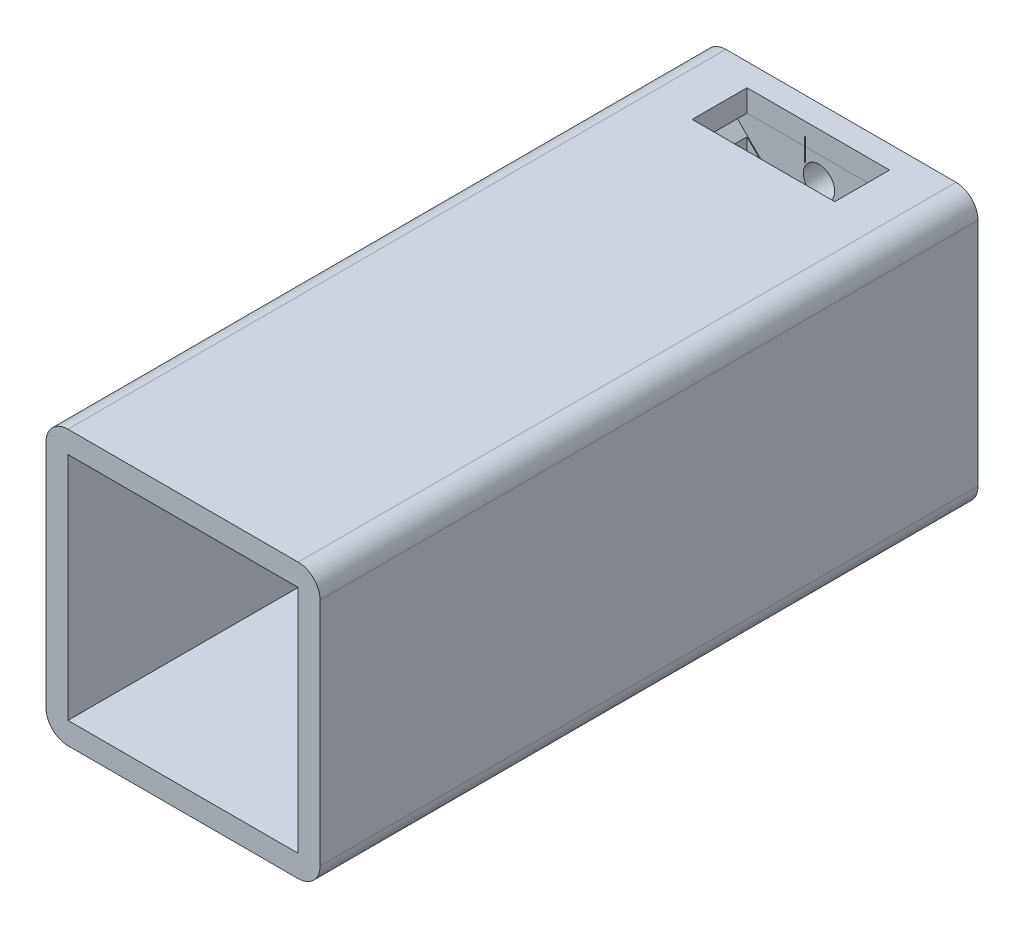
from build123d import *

# Parameters (mm, degrees)
SKETCH1_W           = 25
SKETCH1_H           = 25
BOSS_EXTRUDE1_DEPTH = 60
SHELL1_T            = -2
SKETCH2_R           = 2.5
SKETCH2_R_2         = 1.425
CUT_EXTRUDE4_DEPTH  = 2
BOSS_EXTRUDE3_DEPTH = 30
FILLET1_R           = 2
SKETCH5_W           = 13
SKETCH5_H           = 5
SKETCH5_R           = 0.024622166
CUT_EXTRUDE6_DEPTH  = 10


with BuildPart() as part:
    # Sketch1 → Boss-Extrude1 (new body)
    with BuildSketch(Plane.XY):
        Rectangle(SKETCH1_W, SKETCH1_H)
    extrude(amount=BOSS_EXTRUDE1_DEPTH)

    # Shell1
    shell1_openings = [part.faces().sort_by_distance(p)[0] for p in [
        (0, 0, 60),
    ]]
    offset(amount=SHELL1_T, openings=shell1_openings, kind=Kind.INTERSECTION)

    # Sketch2 → Cut-Extrude4 (cut)
    with BuildSketch(Plane.XY):
        Circle(SKETCH2_R)
        with Locations((8.25, 0)):
            Circle(SKETCH2_R_2)
        with Locations((0, -8.25)):
            Circle(SKETCH2_R_2)
        with Locations((-8.25, 0)):
            Circle(SKETCH2_R_2)
        with Locations((0, 8.25)):
            Circle(SKETCH2_R_2)
    extrude(amount=CUT_EXTRUDE4_DEPTH, mode=Mode.SUBTRACT)

    # Sketch4 → Boss-Extrude3 (add)
    with BuildSketch(Plane.XY.offset(2)):
        with BuildLine():
            Line((-8.871320344, 6.75), (-6.792832126, 4.671511782))
            ThreePointArc((-6.792832126, 4.671511782), (-6.28187766, 5.363494358), (-5.703280287, 6))
            Line((-5.703280287, 6), (-3.878679656, 6))
            Line((-3.878679656, 6), (-4.628679656, 6.75))
            Line((-4.628679656, 6.75), (-8.871320344, 6.75))
        make_face()
        Polygon((-10.5, 8.378679656), (-8.871320344, 6.75), (-4.628679656, 6.75), (-8.378679656, 10.5), (-10.5, 10.5), align=None)
        Polygon((-3.878679656, 6), (0, 6), (3.878679656, 6), (4.628679656, 6.75), (-4.628679656, 6.75), align=None)
        Polygon((8.378679656, 10.5), (4.628679656, 6.75), (8.871320344, 6.75), (10.5, 8.378679656), (10.5, 10.5), align=None)
        with BuildLine():
            Line((4.628679656, 6.75), (3.878679656, 6))
            Line((3.878679656, 6), (4.296719713, 6))
            ThreePointArc((4.296719713, 6), (5.489948643, 5.313054416), (6.513606116, 4.392285772))
            Line((6.513606116, 4.392285772), (8.871320344, 6.75))
            Line((8.871320344, 6.75), (4.628679656, 6.75))
        make_face()
        with BuildLine():
            ThreePointArc((-5.703280287, -6), (-6.28187766, -5.363494358), (-6.792832126, -4.671511782))
            Line((-6.792832126, -4.671511782), (-8.871320344, -6.75))
            Line((-8.871320344, -6.75), (-4.628679656, -6.75))
            Line((-4.628679656, -6.75), (-3.878679656, -6))
            Line((-3.878679656, -6), (-5.703280287, -6))
        make_face()
        with BuildLine():
            Line((4.296719713, -6), (3.878679656, -6))
            Line((3.878679656, -6), (4.628679656, -6.75))
            Line((4.628679656, -6.75), (8.871320344, -6.75))
            Line((8.871320344, -6.75), (6.513606116, -4.392285772))
            ThreePointArc((6.513606116, -4.392285772), (5.489948643, -5.313054416), (4.296719713, -6))
        make_face()
        Polygon((-4.628679656, -6.75), (-8.871320344, -6.75), (-10.5, -8.378679656), (-10.5, -10.5), (-8.378679656, -10.5), align=None)
        Polygon((8.871320344, -6.75), (4.628679656, -6.75), (8.378679656, -10.5), (10.5, -10.5), (10.5, -8.378679656), align=None)
        with BuildLine():
            Line((8.871320344, 6.75), (6.513606116, 4.392285772))
            ThreePointArc((6.513606116, 4.392285772), (7.473760778, 3.000900651), (8.046659593, 1.410417555))
            ThreePointArc((8.046659593, 1.410417555), (8.886964121, 1.274716325), (9.5, 0.684196609))
            Line((9.5, 0.684196609), (9.5, 6.75))
            Line((9.5, 6.75), (8.871320344, 6.75))
        make_face()
        with BuildLine():
            ThreePointArc((8.046659593, -1.410417555), (7.473760778, -3.000900651), (6.513606116, -4.392285772))
            Line((6.513606116, -4.392285772), (8.871320344, -6.75))
            Line((8.871320344, -6.75), (9.5, -6.75))
            Line((9.5, -6.75), (9.5, -0.684196609))
            ThreePointArc((9.5, -0.684196609), (8.886964121, -1.274716325), (8.046659593, -1.410417555))
        make_face()
        Polygon((3.878679656, -6), (0, -6), (-3.878679656, -6), (-4.628679656, -6.75), (4.628679656, -6.75), align=None)
        with BuildLine():
            ThreePointArc((-6.792832126, -4.671511782), (-7.607218745, -3.110608316), (-8.080808179, -1.414920184))
            ThreePointArc((-8.080808179, -1.414920184), (-8.902323398, -1.26692509), (-9.5, -0.684196609))
            Line((-9.5, -0.684196609), (-9.5, -6.75))
            Line((-9.5, -6.75), (-8.871320344, -6.75))
            Line((-8.871320344, -6.75), (-6.792832126, -4.671511782))
        make_face()
        with BuildLine():
            ThreePointArc((-9.5, 0.684196609), (-8.902323398, 1.26692509), (-8.080808179, 1.414920184))
            ThreePointArc((-8.080808179, 1.414920184), (-7.607218745, 3.110608316), (-6.792832126, 4.671511782))
            Line((-6.792832126, 4.671511782), (-8.871320344, 6.75))
            Line((-8.871320344, 6.75), (-9.5, 6.75))
            Line((-9.5, 6.75), (-9.5, 0.684196609))
        make_face()
        with BuildLine():
            ThreePointArc((-8.080808179, -1.414920184), (-8.170149368, -0.709965812), (-8.2, 0))
            ThreePointArc((-8.2, 0), (-8.170149368, 0.709965812), (-8.080808179, 1.414920184))
            ThreePointArc((-8.080808179, 1.414920184), (-8.902323398, 1.26692509), (-9.5, 0.684196609))
            Line((-9.5, 0.684196609), (-9.5, -0.684196609))
            ThreePointArc((-9.5, -0.684196609), (-8.902323398, -1.26692509), (-8.080808179, -1.414920184))
        make_face()
        with BuildLine():
            ThreePointArc((8.046659593, 1.410417555), (8.161552283, 0.709364321), (8.2, 0))
            ThreePointArc((8.2, 0), (8.161552283, -0.709364321), (8.046659593, -1.410417555))
            ThreePointArc((8.046659593, -1.410417555), (8.886964121, -1.274716325), (9.5, -0.684196609))
            Line((9.5, -0.684196609), (9.5, 0.684196609))
            ThreePointArc((9.5, 0.684196609), (8.886964121, 1.274716325), (8.046659593, 1.410417555))
        make_face()
    extrude(amount=BOSS_EXTRUDE3_DEPTH)

    # Fillet1
    fillet1_edges = [part.edges().sort_by_distance(p)[0] for p in [
        (12.5, -12.5, 30),
        (-12.5, -12.5, 30),
        (-12.5, 12.5, 30),
        (12.5, 12.5, 30),
    ]]
    fillet(fillet1_edges, radius=FILLET1_R)

    # Sketch5 → Cut-Extrude6 (cut)
    with BuildSketch(Plane(origin=(0, 12.5, 0), x_dir=(1, 0, 0), z_dir=(0, 1, 0))):
        with Locations((0, -4.566766708)):
            Rectangle(SKETCH5_W, SKETCH5_H)
        with Locations((0.024622166, -3.301323142)):
            Circle(SKETCH5_R, mode=Mode.SUBTRACT)
    extrude(amount=-CUT_EXTRUDE6_DEPTH, mode=Mode.SUBTRACT)


solid = part.part
